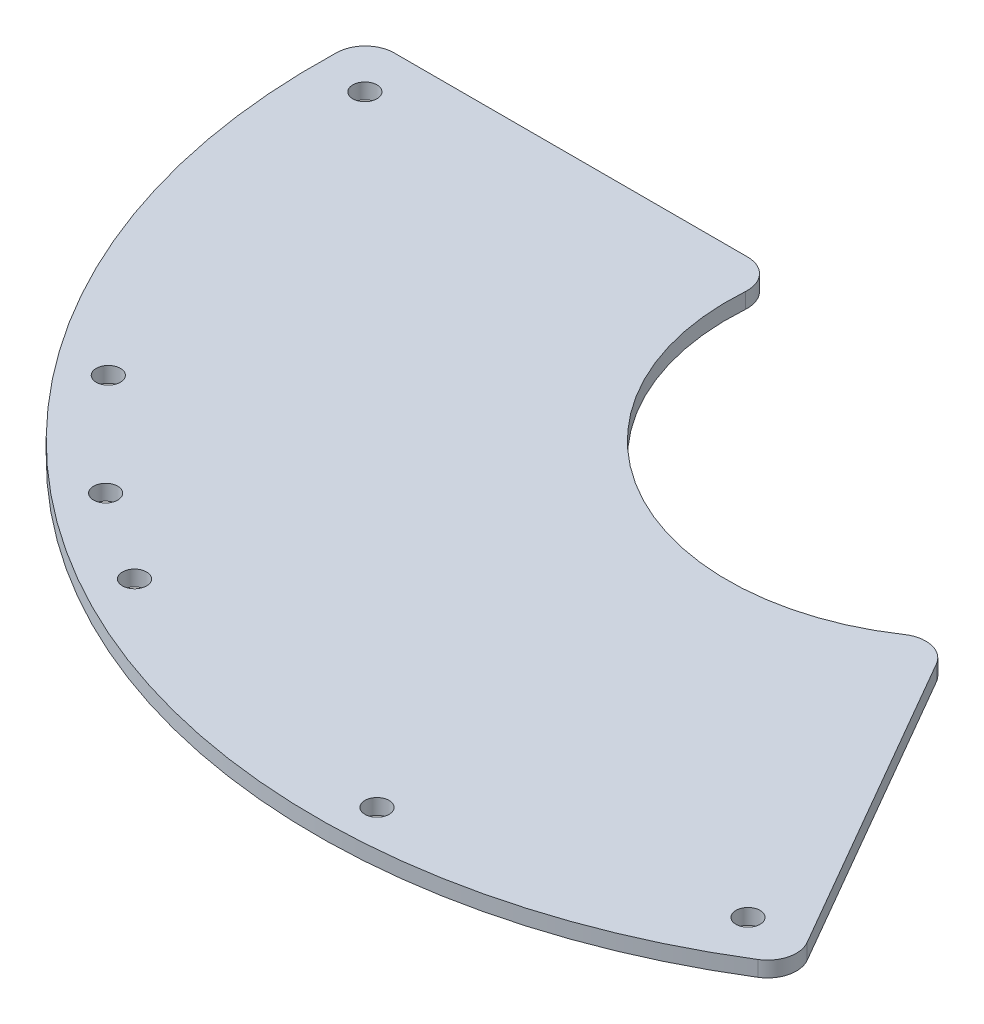
from build123d import *

# Parameters (mm, degrees)
SKETCH1_R           = 1.25
BOSS_EXTRUDE1_DEPTH = 0.8
FILLET1_R           = 3


with BuildPart() as part:
    # Sketch1 → Boss-Extrude1 (new body, symmetric)
    with BuildSketch(Plane(origin=(0, 0, 0), x_dir=(1, 0, 0), z_dir=(0, 1, 0))):
        with BuildLine():
            Line((-67.314560089, 5), (-24.494897428, 5))
            ThreePointArc((-24.494897428, 5), (-12.5, -21.650635095), (16.577575733, -18.713203436))
            Line((16.577575733, -18.713203436), (37.987407064, -55.796119082))
            ThreePointArc((37.987407064, -55.796119082), (-33.75, -58.456714755), (-67.314560089, 5))
        make_face()
        with Locations((-62.5, 0)):
            Circle(SKETCH1_R, mode=Mode.SUBTRACT)
        with Locations((31.25, -54.126587737)):
            Circle(SKETCH1_R, mode=Mode.SUBTRACT)
        with Locations((2.216118041, -63.461317516)):
            Circle(SKETCH1_R, mode=Mode.SUBTRACT)
        with Locations((-30.785410886, -55.538351403)):
            Circle(SKETCH1_R, mode=Mode.SUBTRACT)
        with Locations((-39.961844832, -49.348768553)):
            Circle(SKETCH1_R, mode=Mode.SUBTRACT)
        with Locations((-50.377937108, -38.656350742)):
            Circle(SKETCH1_R, mode=Mode.SUBTRACT)
    extrude(amount=BOSS_EXTRUDE1_DEPTH, both=True)

    # Fillet1
    fillet1_edges = [part.edges().sort_by_distance(p)[0] for p in [
        (-67.314560089, 0, -5),
        (-24.494897428, 0, -5),
        (16.577575733, 0, 18.713203436),
        (37.987407064, 0, 55.796119082),
    ]]
    fillet(fillet1_edges, radius=FILLET1_R)


solid = part.part
